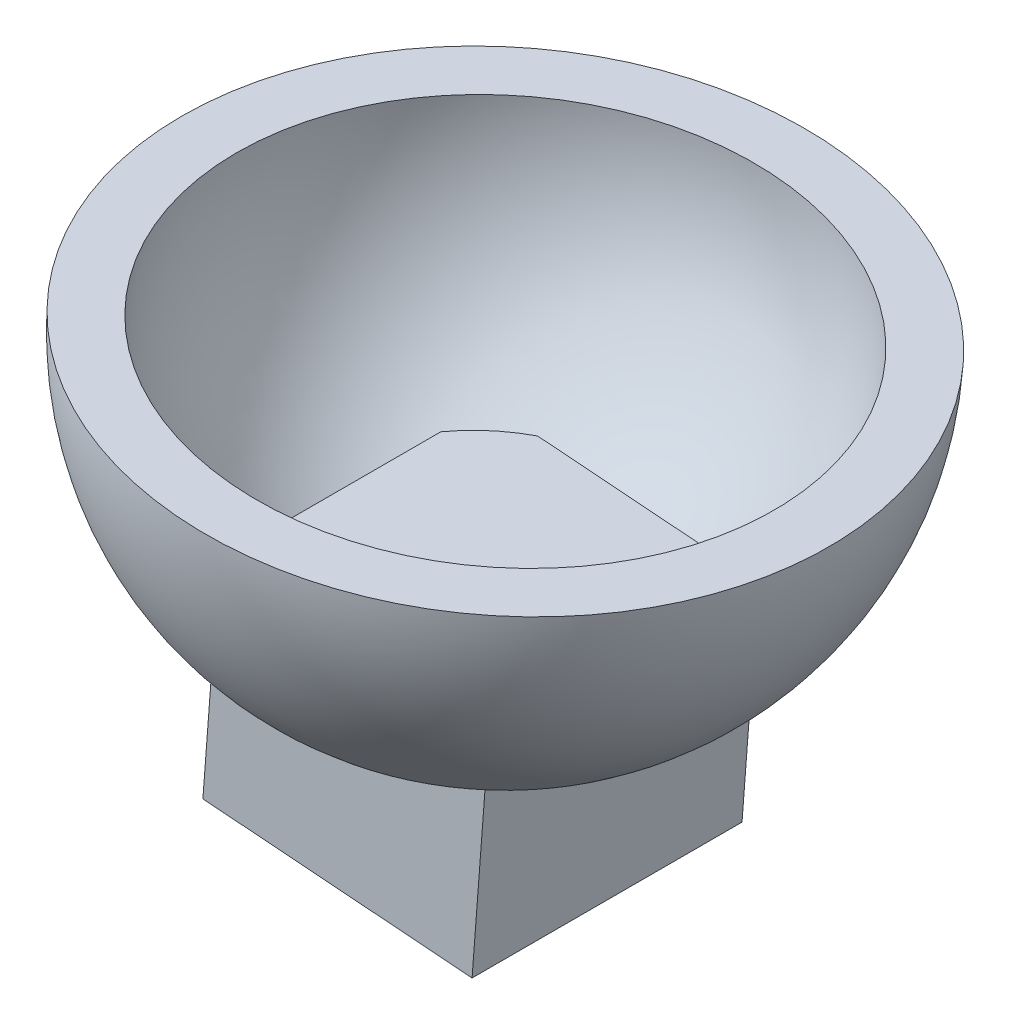
from build123d import *

# Parameters (mm, degrees)
BOSS_EXTRUDE2_DEPTH      = 25.4
BOSS_EXTRUDE2_DEPTH_BACK = 25.4
SKETCH3_W                = 63.5
SKETCH3_H                = 63.5


with BuildPart() as part:
    # Sketch1 → Revolve1 (revolve)
    with BuildSketch(Plane.XY):
        with BuildLine():
            Line((-76.123658673, 5.804761032), (-63.20203376, 4.819430767))
            ThreePointArc((-63.20203376, 4.819430767), (-48.098438833, -41.28273448), (-4.819430767, -63.20203376))
            Line((-4.819430767, -63.20203376), (-5.804761032, -76.123658673))
            ThreePointArc((-5.804761032, -76.123658673), (-57.932141145, -49.722969368), (-76.123658673, 5.804761032))
        make_face()
    revolve(axis=Axis((0, 0, 0), (-0.07603362508452277, -0.9971052541514894, 0)))

    # Sketch3 → Boss-Extrude2 (add, two sides: drawn at the far end of the back side and taken through both)
    with BuildSketch(Plane(origin=(-5.804761032, -76.123658673, 0), x_dir=(-0.9971052541514894, 0.07603362508452276, 0), z_dir=(-0.07603362508452274, -0.9971052541514893, 0)).offset(-BOSS_EXTRUDE2_DEPTH_BACK)):
        Rectangle(SKETCH3_W, SKETCH3_H)
    extrude(amount=BOSS_EXTRUDE2_DEPTH + BOSS_EXTRUDE2_DEPTH_BACK)


solid = part.part
